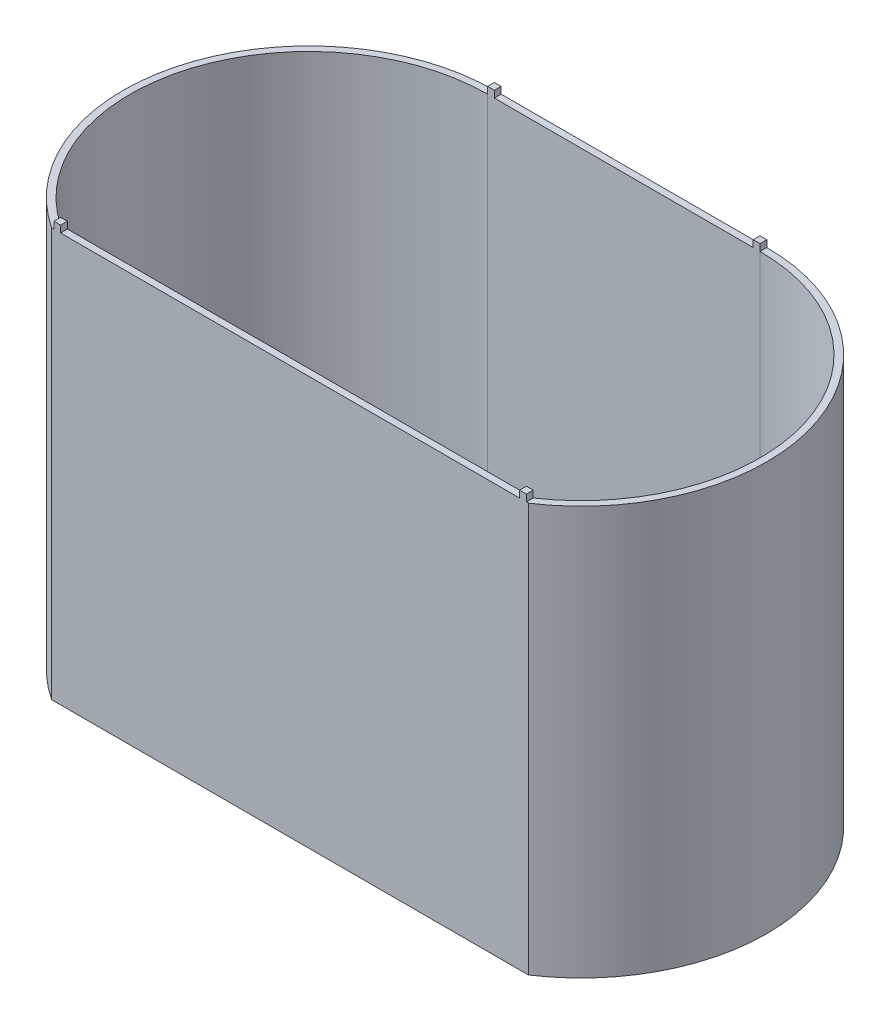
from build123d import *

# Parameters (mm, degrees)
BOSS_EXTRUDE2_DEPTH = 120
SHELL2_T            = -2
SKETCH12_W          = 12
SKETCH12_H          = 10
CUT_EXTRUDE4_DEPTH  = 5
CUT_EXTRUDE8_REACH  = 122
SKETCH22_R          = 1.58
SKETCH22_R_2        = 10
BOSS_EXTRUDE4_DEPTH = 30
CUT_EXTRUDE9_REACH  = 122
SKETCH27_W          = 2
SKETCH27_H          = 2
BOSS_EXTRUDE5_DEPTH = 2


with BuildPart() as part:
    # Sketch1 → Boss-Extrude2 (new body)
    with BuildSketch(Plane(origin=(0, 0, 0), x_dir=(1, 0, 0), z_dir=(0, 1, 0))):
        with BuildLine():
            Line((-77.5, -23.128972286), (62.5, -23.128972286))
            ThreePointArc((62.5, -23.128972286), (84.701532545, 38.031487477), (32.5, 76.871027714))
            Line((32.5, 76.871027714), (-47.5, 76.871027714))
            ThreePointArc((-47.5, 76.871027714), (-99.701532545, 38.031487477), (-77.5, -23.128972286))
        make_face()
    extrude(amount=BOSS_EXTRUDE2_DEPTH)

    # Shell2
    shell2_openings = [part.faces().sort_by_distance(p)[0] for p in [
        (-7.5, 120, -32.451257595),
    ]]
    offset(amount=SHELL2_T, openings=shell2_openings, kind=Kind.INTERSECTION)

    # Sketch12 → Cut-Extrude4 (cut)
    with BuildSketch(Plane(origin=(0, 2, 0), x_dir=(1, 0, 0), z_dir=(0, 1, 0))):
        with Locations((55.893876913, -9.063838959)):
            Rectangle(SKETCH12_W, SKETCH12_H)
    extrude(amount=-CUT_EXTRUDE4_DEPTH, mode=Mode.SUBTRACT)

    # Sketch22 → Cut-Extrude8 (cut, up to next)
    with BuildSketch(Plane(origin=(0, 0, 0), x_dir=(1, 0, 0), z_dir=(0, 1, 0)), mode=Mode.PRIVATE) as cut_extrude8_sk1:
        with Locations((-67.5, -16.628972286)):
            Circle(SKETCH22_R)
    cut_extrude8_tool1 = extrude(cut_extrude8_sk1.sketch, amount=CUT_EXTRUDE8_REACH, mode=Mode.PRIVATE) & part.part
    add(cut_extrude8_tool1.solids().sort_by_distance((-67.5, 0, 16.628972))[0], mode=Mode.SUBTRACT)
    # Sketch22 → Cut-Extrude8 (cut, up to next)
    with BuildSketch(Plane(origin=(0, 0, 0), x_dir=(1, 0, 0), z_dir=(0, 1, 0)), mode=Mode.PRIVATE) as cut_extrude8_sk2:
        with Locations((-67.5, 47.344907447)):
            Circle(SKETCH22_R)
    cut_extrude8_tool2 = extrude(cut_extrude8_sk2.sketch, amount=CUT_EXTRUDE8_REACH, mode=Mode.PRIVATE) & part.part
    add(cut_extrude8_tool2.solids().sort_by_distance((-67.5, 0, -47.344907))[0], mode=Mode.SUBTRACT)
    # Sketch22 → Cut-Extrude8 (cut, up to next)
    with BuildSketch(Plane(origin=(0, 0, 0), x_dir=(1, 0, 0), z_dir=(0, 1, 0)), mode=Mode.PRIVATE) as cut_extrude8_sk3:
        with Locations((-32.5, 26.344907447)):
            Circle(SKETCH22_R_2)
    cut_extrude8_tool3 = extrude(cut_extrude8_sk3.sketch, amount=CUT_EXTRUDE8_REACH, mode=Mode.PRIVATE) & part.part
    add(cut_extrude8_tool3.solids().sort_by_distance((-32.5, 0, -26.344907))[0], mode=Mode.SUBTRACT)

    # Sketch23 → Boss-Extrude4 (add)
    with BuildSketch(Plane(origin=(0, 0, 0), x_dir=(1, 0, 0), z_dir=(0, 1, 0))):
        Polygon((51.893876913, 46.61041607), (51.893876913, 0.61041607), (69.893876913, 0.61041607), (69.893876913, 46.61041607), (71.893876913, 46.61041607), (71.893876913, -1.38958393), (49.893876913, -1.38958393), (49.893876913, 46.61041607), align=None)
    extrude(amount=BOSS_EXTRUDE4_DEPTH)

    # Sketch24 → Cut-Extrude9 (cut, up to next)
    with BuildSketch(Plane(origin=(0, 0, 0), x_dir=(1, 0, 0), z_dir=(0, 1, 0)), mode=Mode.PRIVATE) as cut_extrude9_sk1:
        with BuildLine():
            Line((54.893876913, 56.61041607), (66.893876913, 56.61041607))
            ThreePointArc((66.893876913, 56.61041607), (70.429410819, 55.145949976), (71.893876913, 51.61041607))
            Line((71.893876913, 51.61041607), (71.893876913, 46.61041607))
            Line((71.893876913, 46.61041607), (69.893876913, 46.61041607))
            Line((69.893876913, 46.61041607), (69.893876913, 41.61041607))
            Line((69.893876913, 41.61041607), (51.893876913, 41.61041607))
            Line((51.893876913, 41.61041607), (51.893876913, 46.61041607))
            Line((51.893876913, 46.61041607), (49.893876913, 46.61041607))
            Line((49.893876913, 46.61041607), (49.893876913, 51.61041607))
            ThreePointArc((49.893876913, 51.61041607), (51.358343007, 55.145949976), (54.893876913, 56.61041607))
        make_face()
    cut_extrude9_tool1 = extrude(cut_extrude9_sk1.sketch, amount=CUT_EXTRUDE9_REACH, mode=Mode.PRIVATE) & part.part
    add(cut_extrude9_tool1.solids().sort_by_distance((60.893877, 0, -49.215699))[0], mode=Mode.SUBTRACT)

    # Sketch27 → Boss-Extrude5 (add)
    with BuildSketch(Plane(origin=(0, 120, 0), x_dir=(1, 0, 0), z_dir=(0, 1, 0))):
        with Locations((-46.5, 75.871027714)):
            Rectangle(SKETCH27_W, SKETCH27_H)
        with Locations((31.5, 75.871027714)):
            Rectangle(SKETCH27_W, SKETCH27_H)
        with Locations((60.893876913, -22.128972286)):
            Rectangle(SKETCH27_W, SKETCH27_H)
        with Locations((-75.893876913, -22.128972286)):
            Rectangle(SKETCH27_W, SKETCH27_H)
    extrude(amount=BOSS_EXTRUDE5_DEPTH)


solid = part.part
